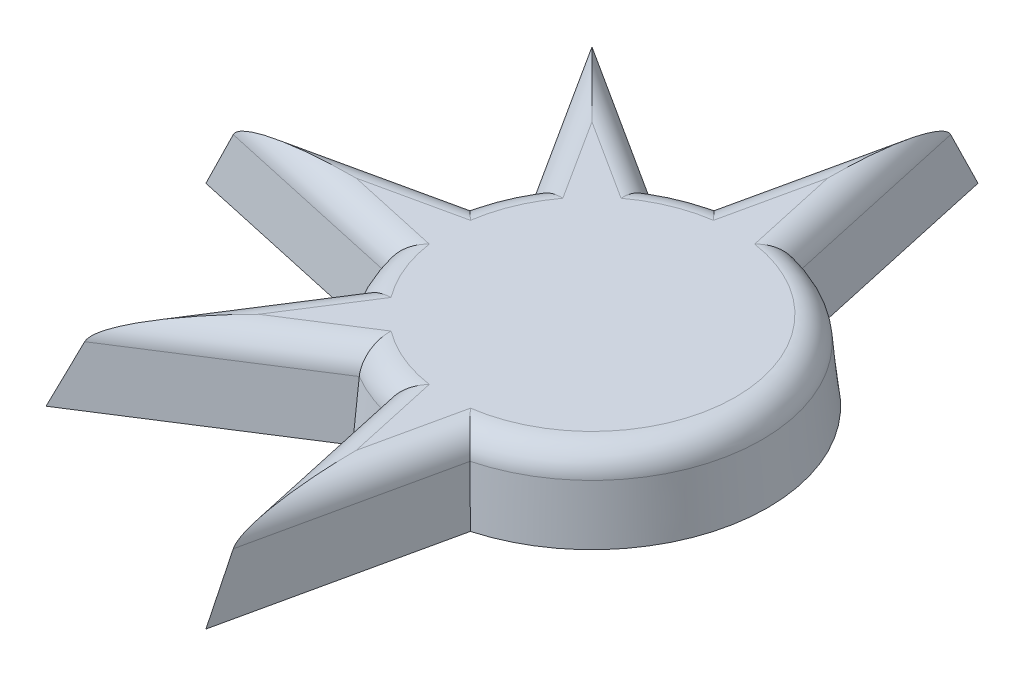
from build123d import *

# Parameters (mm, degrees)
BOSS_EXTRUDE1_DEPTH = 3
BOSS_EXTRUDE1_TAPER = 6
FILLET1_R           = 1


with BuildPart() as part:
    # Sketch2 → Boss-Extrude1 (new body)
    with BuildSketch(Plane(origin=(0, 0, 0), x_dir=(1, 0, 0), z_dir=(0, 1, 0))):
        with BuildLine():
            Line((1.794958228, 6.376825284), (0, 14.54359673))
            Line((0, 14.54359673), (-1.794958228, 6.376825284))
            ThreePointArc((-1.794958228, 6.376825284), (-2.535137681, 6.120363771), (-3.239869266, 5.778323536))
            Line((-3.239869266, 5.778323536), (-10.283875871, 10.283875871))
            Line((-10.283875871, 10.283875871), (-5.778323536, 3.239869266))
            ThreePointArc((-5.778323536, 3.239869266), (-6.120363771, 2.535137681), (-6.376825284, 1.794958228))
            Line((-6.376825284, 1.794958228), (-14.54359673, 0))
            Line((-14.54359673, 0), (-6.376825284, -1.794958228))
            ThreePointArc((-6.376825284, -1.794958228), (-6.120363771, -2.535137681), (-5.778323536, -3.239869266))
            Line((-5.778323536, -3.239869266), (-10.283875871, -10.283875871))
            Line((-10.283875871, -10.283875871), (-3.239869266, -5.778323536))
            ThreePointArc((-3.239869266, -5.778323536), (-2.535137681, -6.120363771), (-1.794958228, -6.376825284))
            Line((-1.794958228, -6.376825284), (0, -14.54359673))
            Line((0, -14.54359673), (1.794958228, -6.376825284))
            ThreePointArc((1.794958228, -6.376825284), (6.624634009, 0), (1.794958228, 6.376825284))
        make_face()
    extrude(amount=BOSS_EXTRUDE1_DEPTH, taper=BOSS_EXTRUDE1_TAPER)

    # Fillet1
    fillet1_edges = [part.edges().sort_by_distance(p)[0] for p in [
        (-9.598084382, 3, -0.764125431),
        (-5.829052816, 3, -2.414472732),
        (-7.327188827, 3, -6.246552279),
        (-6.246552279, 3, -7.327188827),
        (-2.414472732, 3, -5.829052816),
        (-0.764125431, 3, -9.598084382),
        (0.764125431, 3, -9.598084382),
        (6.309321303, 3, 0),
        (0.764125431, 3, 9.598084382),
        (-0.764125431, 3, 9.598084382),
        (-2.414472732, 3, 5.829052816),
        (-6.246552279, 3, 7.327188827),
        (-7.327188827, 3, 6.246552279),
        (-5.829052816, 3, 2.414472732),
        (-9.598084382, 3, 0.764125431),
    ]]
    fillet(fillet1_edges, radius=FILLET1_R)


solid = part.part
